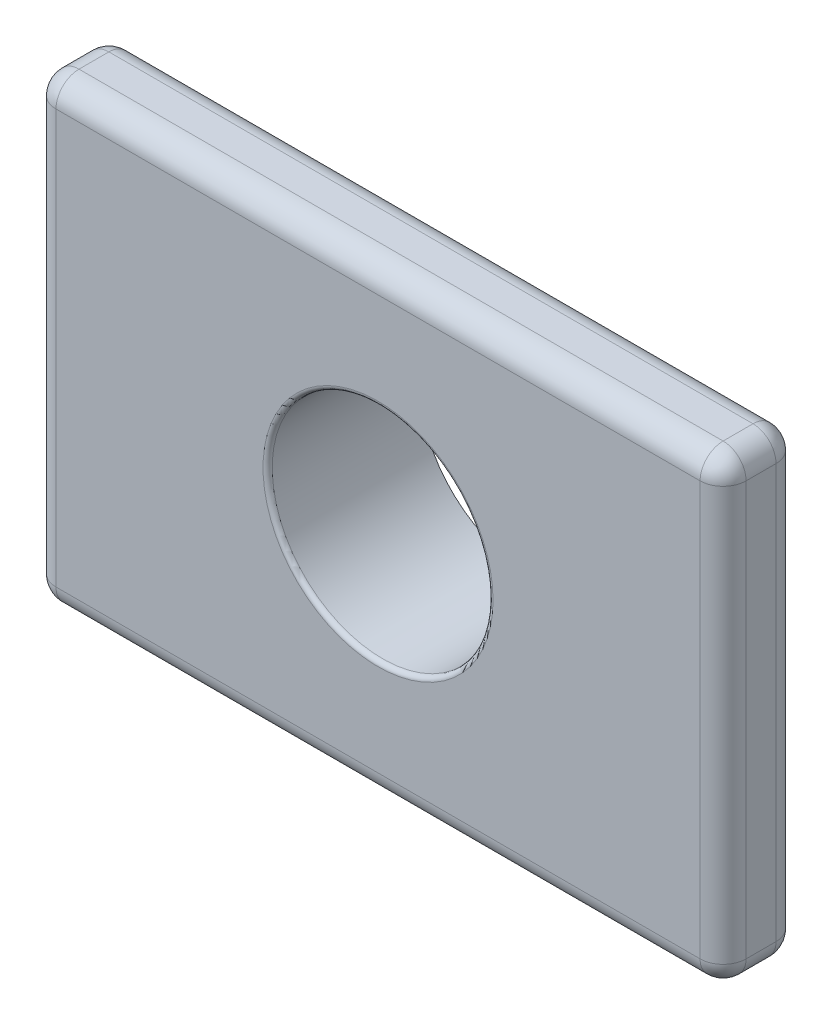
from build123d import *

# Parameters (mm, degrees)
SKETCH1_W           = 15
SKETCH1_H           = 9.998
BOSS_EXTRUDE1_DEPTH = 1.65
SKETCH2_R           = 2.6
BOSS_EXTRUDE2_DEPTH = 1.65
SKETCH3_R           = 2.4
CUT_EXTRUDE1_DEPTH  = 4.3
FILLET1_R           = 0.1
FILLET3_R           = 0.5
FILLET4_R           = 0.5


with BuildPart() as part:
    # Sketch1 → Boss-Extrude1 (new body)
    with BuildSketch(Plane.XY):
        with Locations((7.5, 4.999)):
            Rectangle(SKETCH1_W, SKETCH1_H)
    extrude(amount=BOSS_EXTRUDE1_DEPTH)

    # Sketch2 → Boss-Extrude2 (add)
    with BuildSketch(Plane(origin=(0, 0, 0), x_dir=(-1, 0, 0), z_dir=(0, 0, -1))):
        with Locations((-7.5, 4.999)):
            Circle(SKETCH2_R)
    extrude(amount=BOSS_EXTRUDE2_DEPTH)

    # Sketch3 → Cut-Extrude1 (cut, through all)
    with BuildSketch(Plane.XY.offset(1.65)):
        with Locations((7.5, 4.999)):
            Circle(SKETCH3_R)
    extrude(amount=-CUT_EXTRUDE1_DEPTH, mode=Mode.SUBTRACT)

    # Fillet1
    fillet1_edges = [part.edges().sort_by_distance(p)[0] for p in [
        (10.1, 4.999, 0),
        (10.1, 4.999, -1.65),
        (5.1, 4.999, 1.65),
    ]]
    fillet(fillet1_edges, radius=FILLET1_R)

    # Fillet3
    fillet3_edges = [part.edges().sort_by_distance(p)[0] for p in [
        (0, 0, 0.825),
        (0, 9.998, 0.825),
        (15, 9.998, 0.825),
        (15, 0, 0.825),
    ]]
    fillet(fillet3_edges, radius=FILLET3_R)

    # Fillet4
    fillet4_edges = [part.edges().sort_by_distance(p)[0] for p in [
        (7.5, 9.998, 0),
        (7.5, 9.998, 1.65),
        (7.5, 0, 0),
        (0, 4.999, 0),
        (15, 4.999, 0),
        (0.146446609, 0.146446609, 0),
        (0.146446609, 9.851553391, 0),
        (14.853553391, 0.146446609, 0),
        (14.853553391, 9.851553391, 0),
        (15, 4.999, 1.65),
        (7.5, 0, 1.65),
        (0, 4.999, 1.65),
        (0.146446609, 0.146446609, 1.65),
        (0.146446609, 9.851553391, 1.65),
        (14.853553391, 0.146446609, 1.65),
        (14.853553391, 9.851553391, 1.65),
    ]]
    fillet(fillet4_edges, radius=FILLET4_R)


solid = part.part
